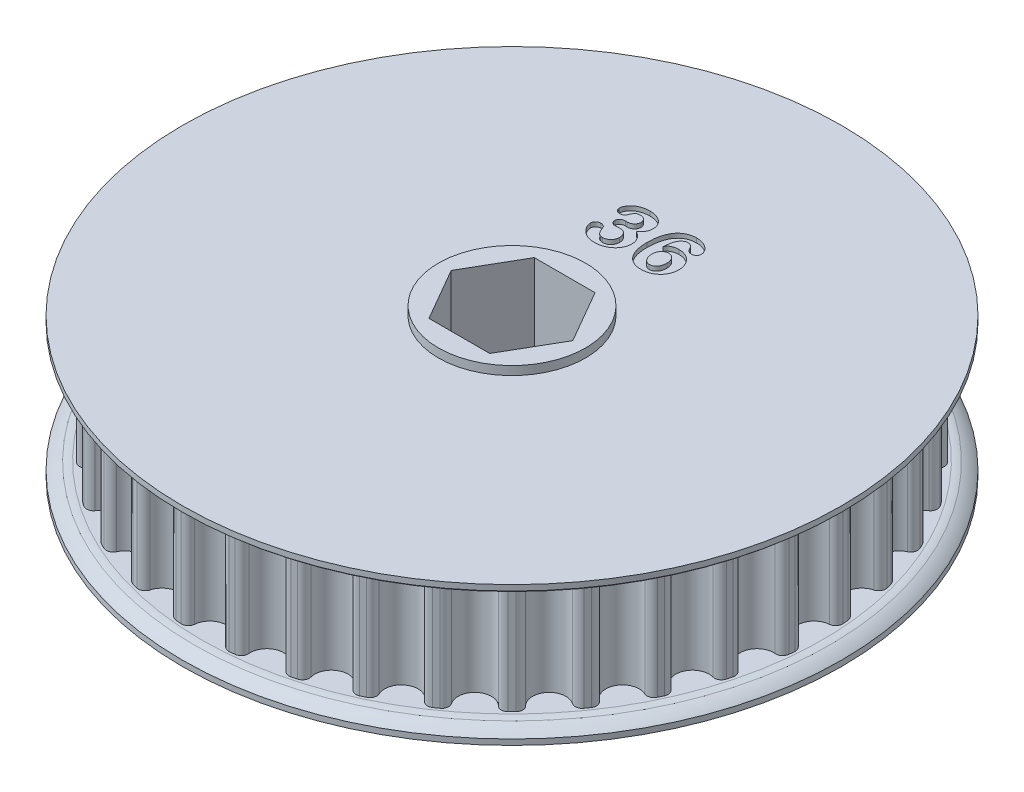
from build123d import *

# Parameters (mm, degrees)
SKETCH1_R               = 28.076389218
TOOTHOD_DEPTH           = 5.08
TOOTHPROFILE_DEPTH      = 11.16
TOOTHPATTERN_COUNT      = 36
SKETCH6_W               = 6.7056
SKETCH6_H               = 0.79375
BORE_DEPTH              = 8.14375
BORE_DEPTH_BACK         = 8.14375
LARGE_TOOTH_COUNT_DEPTH = 0.4


with BuildPart() as part:
    # Sketch1 → ToothOD (new body, symmetric)
    with BuildSketch(Plane(origin=(0, 0, 0), x_dir=(1, 0, 0), z_dir=(0, 1, 0))):
        Circle(SKETCH1_R)
    extrude(amount=TOOTHOD_DEPTH, both=True)

    # Sketch2 → ToothProfile (cut, through all)
    with BuildSketch(Plane(origin=(0, 5.08, 0), x_dir=(1, 0, 0), z_dir=(0, 1, 0))):
        with BuildLine():
            ThreePointArc((-1.519425396, 27.411114635), (0, 26.016389218), (1.519425396, 27.411114635))
            ThreePointArc((1.519425396, 27.411114635), (1.741386688, 27.84115848), (2.201904348, 27.98991334))
            ThreePointArc((2.201904348, 27.98991334), (0, 28.076389218), (-2.201904348, 27.98991334))
            ThreePointArc((-2.201904348, 27.98991334), (-1.741386688, 27.84115848), (-1.519425396, 27.411114635))
        make_face()
    toothprofile = extrude(amount=-TOOTHPROFILE_DEPTH, mode=Mode.SUBTRACT)

    # ToothPattern: ToothProfile ×36 about axis
    toothpattern_axis = Axis((0, 0, 0), (0, 1, 0))
    for i in range(1, TOOTHPATTERN_COUNT):
        add(toothprofile.rotate(toothpattern_axis, i * 360 / TOOTHPATTERN_COUNT), mode=Mode.SUBTRACT)

    # Sketch4 → Flange (revolve)
    with BuildSketch(Plane.XY):
        with BuildLine():
            Line((0, -5.08), (28.330389218, -5.08))
            ThreePointArc((28.330389218, -5.08), (28.656145208, -5.105622571), (28.975961546, -5.172637424))
            ThreePointArc((28.975961546, -5.172637424), (29.543690123, -5.454197125), (30.044889218, -5.842))
            Line((30.044889218, -5.842), (30.044889218, -6.35))
            Line((30.044889218, -6.35), (0, -6.35))
            Line((0, -6.35), (0, -5.08))
        make_face()
        with BuildLine():
            Line((30.044889218, 6.35), (30.044889218, 5.842))
            ThreePointArc((30.044889218, 5.842), (29.543690123, 5.454197125), (28.975961546, 5.172637424))
            ThreePointArc((28.975961546, 5.172637424), (28.656145208, 5.105622571), (28.330389218, 5.08))
            Line((28.330389218, 5.08), (0, 5.08))
            Line((0, 5.08), (0, 6.35))
            Line((0, 6.35), (30.044889218, 6.35))
        make_face()
    revolve(axis=Axis((0, 7.858125, 0), (0, -1, 0)))

    # Sketch6 → TopBearingBoss (revolve)
    with BuildSketch(Plane.XY):
        with Locations((3.3528, 6.746875)):
            Rectangle(SKETCH6_W, SKETCH6_H)
    topbearingboss = revolve(axis=Axis((0, 7.858125, 0), (0, -1, 0)))

    # BottomBearingBoss: TopBearingBoss across plane
    add(topbearingboss.mirror(Plane.ZX))

    # Sketch7 → Bore (cut, two sides)
    with BuildSketch(Plane.XZ) as bore_sk:
        Polygon((2.771627702, 4.8006), (-2.771627702, 4.8006), (-5.543255405, 0), (-2.771627702, -4.8006), (2.771627702, -4.8006), (5.543255405, 0), align=None)
    extrude(amount=BORE_DEPTH, mode=Mode.SUBTRACT)
    extrude(bore_sk.sketch, amount=-BORE_DEPTH_BACK, mode=Mode.SUBTRACT)

    # Sketch9 → Large Tooth Count (cut)
    with BuildSketch(Plane(origin=(0, 6.35, 0), x_dir=(1, 0, 0), z_dir=(0, 1, 0))):
        with BuildLine():
            add(Edge.make_bspline(
                [(-2.157015625, 12.6425445), (-2.111884403, 12.64443398), (-2.023962766, 12.648114937), (-1.897216459, 12.67726646), (-1.781104595, 12.726731958), (-1.693601534, 12.783712382), (-1.631693921, 12.838847998), (-1.590575404, 12.884451281), (-1.556709124, 12.934773106), (-1.528450042, 12.988929014), (-1.506916326, 13.047690391), (-1.490776301, 13.110447299), (-1.481972669, 13.17774376), (-1.480898163, 13.223941999), (-1.48034375, 13.247778875)],
                knots=[0, 0, 0, 0, 0.000135302, 0.000263586, 0.000387613, 0.000512274, 0.000574813, 0.000635952, 0.000695944, 0.000756297, 0.000818773, 0.000883265, 0.000950339, 0.001021838, 0.001021838, 0.001021838, 0.001021838], degree=3))
            add(Edge.make_bspline(
                [(-1.48034375, 13.247778875), (-1.482238566, 13.283364795), (-1.485952272, 13.353110697), (-1.515752857, 13.453681059), (-1.565885328, 13.545781804), (-1.63405775, 13.628860361), (-1.719648386, 13.698830979), (-1.820907936, 13.750391837), (-1.937030222, 13.780560101), (-2.018917057, 13.783832281), (-2.061765625, 13.7855445)],
                knots=[0, 0, 0, 0, 0.000106627, 0.000208981, 0.000311527, 0.000419384, 0.000529405, 0.000640782, 0.000757742, 0.000886119, 0.000886119, 0.000886119, 0.000886119], degree=3))
            add(Edge.make_bspline(
                [(-2.061765625, 13.7855445), (-2.087894348, 13.784798264), (-2.137273817, 13.783387987), (-2.207643435, 13.777621349), (-2.269228007, 13.763082752), (-2.339645218, 13.740430156), (-2.416427882, 13.698077136), (-2.478616997, 13.637961207), (-2.522489539, 13.58024074), (-2.555638687, 13.527943844), (-2.589514573, 13.466379276), (-2.635682542, 13.375118229), (-2.687950603, 13.258408518), (-2.730118411, 13.166063409), (-2.75034375, 13.121771063)],
                knots=[0, 0, 0, 0, 7.8439e-05, 0.000148239, 0.000211303, 0.00026778, 0.000369932, 0.000470998, 0.000524778, 0.000587255, 0.000656544, 0.000735528, 0.000894011, 0.001040092, 0.001040092, 0.001040092, 0.001040092], degree=3))
            add(Edge.make_bspline(
                [(-2.75034375, 13.121771063), (-2.757771996, 13.110721583), (-2.773641193, 13.087116227), (-2.810649943, 13.059211151), (-2.855633248, 13.030698188), (-2.931490979, 12.99738509), (-3.039950355, 12.96480618), (-3.131711281, 12.961008264), (-3.17896875, 12.959052313)],
                knots=[0, 0, 0, 0, 3.9687e-05, 8.4786e-05, 0.000137372, 0.000199532, 0.000332685, 0.000474078, 0.000474078, 0.000474078, 0.000474078], degree=3))
            add(Edge.make_bspline(
                [(-3.17896875, 12.959052313), (-3.204938271, 12.960613704), (-3.256573514, 12.963718221), (-3.331495307, 12.987841238), (-3.40230673, 13.026682965), (-3.467997078, 13.079340406), (-3.523717873, 13.145871748), (-3.565406261, 13.223624155), (-3.589579301, 13.312181316), (-3.592294359, 13.374298209), (-3.593703125, 13.406528875)],
                knots=[0, 0, 0, 0, 7.7797e-05, 0.000154683, 0.00023371, 0.00031909, 0.000405729, 0.000492283, 0.000581828, 0.000678397, 0.000678397, 0.000678397, 0.000678397], degree=3))
            add(Edge.make_bspline(
                [(-3.593703125, 13.406528875), (-3.592354178, 13.437737555), (-3.589612878, 13.501159142), (-3.567007679, 13.596325165), (-3.533407682, 13.693049267), (-3.485225112, 13.790535628), (-3.423416275, 13.887134064), (-3.350245812, 13.98260913), (-3.263570061, 14.073922854), (-3.166964607, 14.163585767), (-3.056818069, 14.247189171), (-2.932844482, 14.321039036), (-2.797615103, 14.388315888), (-2.649715523, 14.443686116), (-2.492341254, 14.491317797), (-2.325048482, 14.523079746), (-2.149919042, 14.543581666), (-2.03040642, 14.546206601), (-1.969492188, 14.5475445)],
                knots=[0, 0, 0, 0, 9.3524e-05, 0.000190057, 0.00029204, 0.000400312, 0.000515371, 0.000635635, 0.000760587, 0.000892604, 0.001030718, 0.001174503, 0.001324927, 0.001483211, 0.001647717, 0.001817589, 0.001993338, 0.002176033, 0.002176033, 0.002176033, 0.002176033], degree=3))
            add(Edge.make_bspline(
                [(-1.969492188, 14.5475445), (-1.912894825, 14.546414192), (-1.801724571, 14.544194005), (-1.638349094, 14.52632416), (-1.482271569, 14.495150086), (-1.333430176, 14.453981191), (-1.192945691, 14.401255934), (-1.062121843, 14.338295139), (-0.941526311, 14.263986326), (-0.832317342, 14.180006344), (-0.733755782, 14.089150126), (-0.64868222, 13.991461033), (-0.577666947, 13.887420287), (-0.52013697, 13.778074395), (-0.475258819, 13.664597947), (-0.443320051, 13.547515782), (-0.42390755, 13.427357492), (-0.421762782, 13.346076195), (-0.4206875, 13.30532575)],
                knots=[0, 0, 0, 0, 0.000169768, 0.000333464, 0.000492245, 0.000646797, 0.000796253, 0.000941804, 0.001081684, 0.001220399, 0.001354491, 0.001483205, 0.001608145, 0.001731528, 0.001853131, 0.00197348, 0.002095006, 0.00221719, 0.00221719, 0.00221719, 0.00221719], degree=3))
            add(Edge.make_bspline(
                [(-0.4206875, 13.30532575), (-0.422150739, 13.252260546), (-0.424989309, 13.14931815), (-0.454296651, 13.000359941), (-0.498779455, 12.861412694), (-0.565247949, 12.733853939), (-0.646829155, 12.6159351), (-0.739747774, 12.502422794), (-0.846598571, 12.395561369), (-0.926107915, 12.330976695), (-0.966390625, 12.298255438)],
                knots=[0, 0, 0, 0, 0.000159001, 0.00030845, 0.000453719, 0.000595272, 0.000738099, 0.000883305, 0.001034846, 0.001190468, 0.001190468, 0.001190468, 0.001190468], degree=3))
            add(Edge.make_bspline(
                [(-0.966390625, 12.298255438), (-0.929596957, 12.279117352), (-0.855339609, 12.240492676), (-0.750874003, 12.169172126), (-0.649933688, 12.089772955), (-0.555598855, 12.00089449), (-0.468741546, 11.905809295), (-0.393120482, 11.805619774), (-0.329551688, 11.701407165), (-0.279407628, 11.592893016), (-0.239035274, 11.48150897), (-0.211379469, 11.366015917), (-0.194077842, 11.247061226), (-0.191698936, 11.166228434), (-0.1905, 11.125489813)],
                knots=[0, 0, 0, 0, 0.000124321, 0.000250905, 0.000378744, 0.000509306, 0.000639252, 0.000764665, 0.000885308, 0.001004709, 0.001122709, 0.001240144, 0.001360395, 0.001482579, 0.001482579, 0.001482579, 0.001482579], degree=3))
            add(Edge.make_bspline(
                [(-0.1905, 11.125489813), (-0.192094678, 11.076452759), (-0.195290193, 10.97818928), (-0.219203507, 10.831631831), (-0.256780918, 10.685916403), (-0.310455948, 10.542693806), (-0.378572049, 10.403116493), (-0.464141536, 10.270797744), (-0.563229415, 10.144043845), (-0.678927942, 10.0263175), (-0.807544592, 9.917389593), (-0.94923826, 9.819008261), (-1.105358046, 9.735376279), (-1.272377153, 9.661545302), (-1.451089398, 9.60293784), (-1.639934199, 9.56185274), (-1.837742142, 9.53483438), (-1.973038792, 9.532323073), (-2.041921875, 9.5310445)],
                knots=[0, 0, 0, 0, 0.000147058, 0.000294684, 0.00044437, 0.00059789, 0.00075275, 0.000909359, 0.001069741, 0.001234626, 0.00140359, 0.001574776, 0.001751042, 0.001934092, 0.002122035, 0.002314133, 0.002513256, 0.002719784, 0.002719784, 0.002719784, 0.002719784], degree=3))
            add(Edge.make_bspline(
                [(-2.041921875, 9.5310445), (-2.108499969, 9.53263626), (-2.238253631, 9.53573843), (-2.427698578, 9.563553956), (-2.606627735, 9.607259017), (-2.773658652, 9.670610818), (-2.927580021, 9.746750057), (-3.068531686, 9.8326532), (-3.196190231, 9.926426748), (-3.30841846, 10.030086414), (-3.406020495, 10.139709066), (-3.492980506, 10.250584634), (-3.566957319, 10.364014336), (-3.626709959, 10.478389222), (-3.674158466, 10.58895269), (-3.707794555, 10.692278721), (-3.730935456, 10.786144569), (-3.734099838, 10.846242417), (-3.735585938, 10.874466375)],
                knots=[0, 0, 0, 0, 0.00019963, 0.000389057, 0.000573147, 0.000751169, 0.000923779, 0.001087646, 0.001245802, 0.001398177, 0.00154501, 0.001685723, 0.001820573, 0.00195061, 0.002072423, 0.002180985, 0.002276549, 0.002361171, 0.002361171, 0.002361171, 0.002361171], degree=3))
            add(Edge.make_bspline(
                [(-3.735585938, 10.874466375), (-3.734032608, 10.908737804), (-3.731024388, 10.975108747), (-3.703162094, 11.068925551), (-3.659172955, 11.153112422), (-3.5953715, 11.222975258), (-3.520183416, 11.280795853), (-3.434611134, 11.32294875), (-3.340524194, 11.348714044), (-3.275046292, 11.351349555), (-3.241476563, 11.35270075)],
                knots=[0, 0, 0, 0, 0.000102585, 0.000198668, 0.000291, 0.00038518, 0.000480036, 0.000574106, 0.000669655, 0.00077018, 0.00077018, 0.00077018, 0.00077018], degree=3))
            add(Edge.make_bspline(
                [(-3.241476563, 11.35270075), (-3.218602924, 11.351603225), (-3.173488087, 11.34943852), (-3.106820151, 11.336469932), (-3.04284117, 11.31319361), (-2.983219438, 11.281768881), (-2.929645336, 11.247522156), (-2.8870894, 11.211334238), (-2.852576409, 11.177414837), (-2.840334224, 11.150718847), (-2.834679688, 11.13838825)],
                knots=[0, 0, 0, 0, 6.864e-05, 0.000135383, 0.000202859, 0.000272085, 0.000337306, 0.000392948, 0.000440001, 0.000480389, 0.000480389, 0.000480389, 0.000480389], degree=3))
            add(Edge.make_bspline(
                [(-2.834679688, 11.13838825), (-2.820311557, 11.101274305), (-2.792459848, 11.02933128), (-2.7491029, 10.926277989), (-2.705207879, 10.832244401), (-2.662976882, 10.7459279), (-2.618801115, 10.669123621), (-2.577075586, 10.598841195), (-2.532761662, 10.538726413), (-2.477763144, 10.468824929), (-2.399118743, 10.397704823), (-2.290202773, 10.336113991), (-2.166615271, 10.299170017), (-2.079882194, 10.295134085), (-2.034976563, 10.2930445)],
                knots=[0, 0, 0, 0, 0.000119393, 0.000231435, 0.000335312, 0.000430712, 0.000519567, 0.000601077, 0.000675703, 0.000743419, 0.00086776, 0.000990827, 0.001116082, 0.001250556, 0.001250556, 0.001250556, 0.001250556], degree=3))
            add(Edge.make_bspline(
                [(-2.034976563, 10.2930445), (-2.003806077, 10.294232786), (-1.941674855, 10.29660136), (-1.849507969, 10.314471946), (-1.75889532, 10.341715283), (-1.671599601, 10.382118359), (-1.58781549, 10.431823988), (-1.512118592, 10.49559363), (-1.44314573, 10.569315349), (-1.382772856, 10.65396479), (-1.331662747, 10.747344641), (-1.296477219, 10.849709531), (-1.273414798, 10.958103568), (-1.271154957, 11.032762781), (-1.27, 11.0709195)],
                knots=[0, 0, 0, 0, 9.3455e-05, 0.000186282, 0.000280748, 0.000376658, 0.00047416, 0.000572105, 0.000672493, 0.000776299, 0.00088328, 0.000990602, 0.001099959, 0.001214272, 0.001214272, 0.001214272, 0.001214272], degree=3))
            add(Edge.make_bspline(
                [(-1.27, 11.0709195), (-1.270560286, 11.099383177), (-1.271657679, 11.15513302), (-1.280514674, 11.236154242), (-1.295659925, 11.312416525), (-1.315634417, 11.384013578), (-1.344559164, 11.449800178), (-1.376581011, 11.512164184), (-1.416894679, 11.568397932), (-1.461626204, 11.620680977), (-1.511934133, 11.666930068), (-1.567372981, 11.707500229), (-1.627994429, 11.740745799), (-1.693291801, 11.76915947), (-1.763628774, 11.790420281), (-1.838866572, 11.806791751), (-1.919022226, 11.815316155), (-1.974105141, 11.816460247), (-2.002234375, 11.8170445)],
                knots=[0, 0, 0, 0, 8.538e-05, 0.000167228, 0.000244089, 0.000318503, 0.000389637, 0.000459323, 0.000528414, 0.000596644, 0.000665457, 0.000732933, 0.000802223, 0.000872444, 0.000946194, 0.001022282, 0.001103144, 0.001187533, 0.001187533, 0.001187533, 0.001187533], degree=3))
            add(Edge.make_bspline(
                [(-2.002234375, 11.8170445), (-2.013149109, 11.816737884), (-2.038625164, 11.816022212), (-2.082313291, 11.81411827), (-2.136885798, 11.809957221), (-2.19803711, 11.804265221), (-2.258501955, 11.798317022), (-2.310435325, 11.794275447), (-2.350811539, 11.792287851), (-2.373642425, 11.791555365), (-2.383234375, 11.791247625)],
                knots=[0, 0, 0, 0, 3.2757e-05, 7.6459e-05, 0.000131173, 0.000196927, 0.000260706, 0.000313441, 0.000353178, 0.000381969, 0.000381969, 0.000381969, 0.000381969], degree=3))
            add(Edge.make_bspline(
                [(-2.383234375, 11.791247625), (-2.416103873, 11.792413719), (-2.478614259, 11.794631367), (-2.566842115, 11.815825856), (-2.644072814, 11.850765193), (-2.70956862, 11.900062371), (-2.762416451, 11.962121184), (-2.797566853, 12.037010123), (-2.821995063, 12.120783855), (-2.823809627, 12.180651691), (-2.824757813, 12.211935125)],
                knots=[0, 0, 0, 0, 9.8472e-05, 0.000187271, 0.000270289, 0.000351054, 0.000431341, 0.0005121, 0.000597554, 0.000691078, 0.000691078, 0.000691078, 0.000691078], degree=3))
            add(Edge.make_bspline(
                [(-2.824757813, 12.211935125), (-2.823142272, 12.242905097), (-2.820022845, 12.302704636), (-2.792978858, 12.387374025), (-2.749739761, 12.462964643), (-2.687372417, 12.526690802), (-2.610407925, 12.580733841), (-2.515839245, 12.615994968), (-2.408234977, 12.639836531), (-2.33146158, 12.641609302), (-2.290960938, 12.6425445)],
                knots=[0, 0, 0, 0, 9.2705e-05, 0.000179002, 0.00026392, 0.000351643, 0.00044439, 0.000543698, 0.000652287, 0.000773533, 0.000773533, 0.000773533, 0.000773533], degree=3))
            Line((-2.290960938, 12.6425445), (-2.157015625, 12.6425445))
        make_face()
        with BuildLine():
            add(Edge.make_bspline(
                [(1.447601563, 12.301232), (1.453009879, 12.322245396), (1.463707408, 12.363809428), (1.48930573, 12.422939345), (1.520989673, 12.47868255), (1.559685207, 12.530677031), (1.606344705, 12.577244267), (1.658377002, 12.621608552), (1.717708529, 12.662219731), (1.807322768, 12.709294383), (1.927365138, 12.758241872), (2.079320085, 12.803230441), (2.239913343, 12.827444762), (2.349427302, 12.831158069), (2.4050625, 12.8330445)],
                knots=[0, 0, 0, 0, 6.5009e-05, 0.000128587, 0.000192581, 0.000257073, 0.000322324, 0.000389909, 0.000462012, 0.000537477, 0.000693175, 0.000850179, 0.001011835, 0.001178762, 0.001178762, 0.001178762, 0.001178762], degree=3))
            add(Edge.make_bspline(
                [(2.4050625, 12.8330445), (2.462355944, 12.831529535), (2.57546434, 12.8285387), (2.741556302, 12.804538772), (2.90072962, 12.763423945), (3.052445157, 12.70668638), (3.1959965, 12.636524721), (3.329662088, 12.553837694), (3.452850278, 12.459242339), (3.563565946, 12.351469737), (3.664347231, 12.234239054), (3.75268027, 12.107369441), (3.827722686, 11.970840658), (3.88927345, 11.827006132), (3.939068311, 11.678397036), (3.975084362, 11.527065608), (3.9964143, 11.373819845), (3.999138881, 11.271075564), (4.0005, 11.219747625)],
                knots=[0, 0, 0, 0, 0.000171832, 0.00033923, 0.000502148, 0.000664145, 0.000824333, 0.000980725, 0.001134926, 0.0012893, 0.001443409, 0.001598091, 0.001752187, 0.001909958, 0.002066836, 0.002221821, 0.002376032, 0.002529978, 0.002529978, 0.002529978, 0.002529978], degree=3))
            add(Edge.make_bspline(
                [(4.0005, 11.219747625), (3.997850892, 11.144481621), (3.992629458, 10.996131166), (3.950418741, 10.778252474), (3.881897673, 10.569286396), (3.801157402, 10.404307837), (3.725072769, 10.27834675), (3.660166448, 10.189465496), (3.590675899, 10.104607669), (3.515025506, 10.024693984), (3.43247029, 9.950854099), (3.344866238, 9.88052633), (3.250525665, 9.816651293), (3.151379545, 9.756963092), (3.047647798, 9.703090996), (2.938962341, 9.658205487), (2.827812576, 9.61759748), (2.712185632, 9.586250644), (2.593225173, 9.561547637), (2.470694395, 9.543320757), (2.344689434, 9.533834398), (2.259555191, 9.53198087), (2.216546875, 9.5310445)],
                knots=[0, 0, 0, 0, 0.000225655, 0.000444769, 0.000663144, 0.000883689, 0.000994126, 0.001104276, 0.00121353, 0.001323012, 0.001434004, 0.001545571, 0.001659781, 0.001775489, 0.001892638, 0.002010023, 0.002128022, 0.002247415, 0.002369034, 0.002492373, 0.002618771, 0.002747816, 0.002747816, 0.002747816, 0.002747816], degree=3))
            add(Edge.make_bspline(
                [(2.216546875, 9.5310445), (2.169533289, 9.53154025), (2.07727261, 9.532513122), (1.941632495, 9.548090923), (1.810570719, 9.567240853), (1.684978997, 9.599324829), (1.56329832, 9.636950514), (1.447660878, 9.686665279), (1.335319823, 9.741587568), (1.229537567, 9.807453121), (1.128964082, 9.881371586), (1.033188343, 9.962354746), (0.945264872, 10.053013065), (0.863171408, 10.151279999), (0.786777878, 10.257109286), (0.717395456, 10.371876531), (0.653911432, 10.494225195), (0.59608377, 10.624274424), (0.546192482, 10.762496385), (0.500685089, 10.907494566), (0.464994093, 11.060625275), (0.433755593, 11.220701505), (0.410185375, 11.388302619), (0.393891402, 11.563132462), (0.38204873, 11.745114759), (0.381354334, 11.868948792), (0.381, 11.93213825)],
                knots=[0, 0, 0, 0, 0.000140947, 0.000276597, 0.000409213, 0.000537957, 0.000665038, 0.000790893, 0.000915135, 0.001039871, 0.0011641, 0.001289368, 0.00141566, 0.001542443, 0.001673239, 0.001806816, 0.001944387, 0.002086533, 0.002233437, 0.002385022, 0.002542167, 0.002704843, 0.002874205, 0.003049643, 0.003231541, 0.003421072, 0.003421072, 0.003421072, 0.003421072], degree=3))
            add(Edge.make_bspline(
                [(0.381, 11.93213825), (0.382362514, 12.033395978), (0.385025082, 12.23126951), (0.410432123, 12.519874591), (0.450601925, 12.792702414), (0.50666856, 13.048858723), (0.578461946, 13.286965623), (0.665538683, 13.504912727), (0.766670401, 13.702231072), (0.883464174, 13.878059879), (1.013966085, 14.03412753), (1.158335063, 14.170044597), (1.31700515, 14.285112815), (1.488245224, 14.381049202), (1.673062745, 14.455498093), (1.869453427, 14.509072344), (2.077565864, 14.541392526), (2.220068347, 14.545462885), (2.292945313, 14.5475445)],
                knots=[0, 0, 0, 0, 0.000303713, 0.000593503, 0.000868389, 0.001130547, 0.001379443, 0.001613618, 0.001833725, 0.002043415, 0.002245532, 0.002442778, 0.002636671, 0.002832109, 0.003030174, 0.003232845, 0.003441649, 0.003660202, 0.003660202, 0.003660202, 0.003660202], degree=3))
            add(Edge.make_bspline(
                [(2.292945313, 14.5475445), (2.367513826, 14.54574969), (2.513208573, 14.542242921), (2.724510265, 14.506103442), (2.923143918, 14.450260135), (3.105512799, 14.370429952), (3.269826261, 14.27628259), (3.413656116, 14.171495364), (3.535182954, 14.057622638), (3.631275314, 13.933929601), (3.705135168, 13.808448608), (3.760020033, 13.685995045), (3.793967421, 13.566425653), (3.798754158, 13.487420902), (3.801070313, 13.449192938)],
                knots=[0, 0, 0, 0, 0.000223509, 0.0004367, 0.000641131, 0.000841113, 0.001032235, 0.001208258, 0.001373885, 0.001530088, 0.001676428, 0.00180971, 0.001931975, 0.002046597, 0.002046597, 0.002046597, 0.002046597], degree=3))
            add(Edge.make_bspline(
                [(3.801070313, 13.449192938), (3.799601046, 13.42547896), (3.796603269, 13.377094782), (3.768961689, 13.306029844), (3.728027039, 13.235017818), (3.671021084, 13.166977969), (3.600760369, 13.105228394), (3.513789835, 13.062680082), (3.415028867, 13.03598358), (3.34485337, 13.033033326), (3.307953125, 13.031482)],
                knots=[0, 0, 0, 0, 7.0891e-05, 0.000144641, 0.000225988, 0.000316184, 0.000409813, 0.000504327, 0.000603966, 0.000714461, 0.000714461, 0.000714461, 0.000714461], degree=3))
            add(Edge.make_bspline(
                [(3.307953125, 13.031482), (3.281406916, 13.032636954), (3.228694625, 13.034930323), (3.151295917, 13.053061051), (3.078352533, 13.084985117), (3.008723369, 13.125908604), (2.946420213, 13.179169588), (2.890788452, 13.240814306), (2.846238753, 13.313336941), (2.823461153, 13.36587697), (2.811859375, 13.39263825)],
                knots=[0, 0, 0, 0, 7.9598e-05, 0.000158056, 0.000236746, 0.000317742, 0.000399427, 0.000481659, 0.000565901, 0.000653355, 0.000653355, 0.000653355, 0.000653355], degree=3))
            add(Edge.make_bspline(
                [(2.811859375, 13.39263825), (2.799506329, 13.421533329), (2.775304886, 13.478143057), (2.72415789, 13.554813016), (2.663714481, 13.622352813), (2.593835938, 13.680237415), (2.516396614, 13.727070277), (2.431842539, 13.761491383), (2.340828568, 13.781417182), (2.278157852, 13.784153881), (2.2463125, 13.7855445)],
                knots=[0, 0, 0, 0, 9.4106e-05, 0.000184368, 0.000275005, 0.000365202, 0.000455556, 0.000545468, 0.000637912, 0.000733415, 0.000733415, 0.000733415, 0.000733415], degree=3))
            add(Edge.make_bspline(
                [(2.2463125, 13.7855445), (2.224717521, 13.784623062), (2.180304603, 13.782728002), (2.113385725, 13.765389896), (2.044326016, 13.739541377), (1.97407994, 13.70249927), (1.903707052, 13.655192019), (1.83548507, 13.595216235), (1.768913857, 13.524046445), (1.729140583, 13.469498921), (1.708546875, 13.441255438)],
                knots=[0, 0, 0, 0, 6.4683e-05, 0.000133029, 0.000206188, 0.000285625, 0.000370659, 0.000459983, 0.000557566, 0.000662344, 0.000662344, 0.000662344, 0.000662344], degree=3))
            add(Edge.make_bspline(
                [(1.708546875, 13.441255438), (1.690316305, 13.412540787), (1.651993771, 13.352179635), (1.605936116, 13.248176189), (1.565937201, 13.128709406), (1.53044734, 12.99381257), (1.500781627, 12.843032474), (1.477887866, 12.676660945), (1.458476926, 12.49437507), (1.451328579, 12.367422648), (1.447601563, 12.301232)],
                knots=[0, 0, 0, 0, 0.000101925, 0.000214257, 0.000340078, 0.000479662, 0.000632411, 0.000800791, 0.000983337, 0.001182193, 0.001182193, 0.001182193, 0.001182193], degree=3))
        make_face()
        with BuildLine():
            add(Edge.make_bspline(
                [(2.212578125, 10.2930445), (2.237439246, 10.293755054), (2.286461915, 10.295156167), (2.358198055, 10.30782921), (2.427029087, 10.326108949), (2.492228211, 10.353459978), (2.554206493, 10.388381777), (2.612640232, 10.431548854), (2.668765789, 10.481112161), (2.720073976, 10.539157632), (2.767254555, 10.602682763), (2.80852425, 10.672150424), (2.842971429, 10.746750978), (2.872055965, 10.826271709), (2.893687314, 10.911444906), (2.909169399, 11.001355628), (2.919720354, 11.096468491), (2.92056554, 11.161509339), (2.921, 11.194942938)],
                knots=[0, 0, 0, 0, 7.452e-05, 0.000146943, 0.000217952, 0.000287787, 0.000358427, 0.000430864, 0.00050535, 0.000582639, 0.00066281, 0.000742445, 0.000824563, 0.000908993, 0.000996108, 0.001087782, 0.00118256, 0.001282815, 0.001282815, 0.001282815, 0.001282815], degree=3))
            add(Edge.make_bspline(
                [(2.921, 11.194942938), (2.919903701, 11.239646659), (2.91778285, 11.326128428), (2.900226752, 11.450791052), (2.869183792, 11.564870051), (2.827336011, 11.668668458), (2.776405368, 11.762192361), (2.714833277, 11.843673021), (2.645517535, 11.913790958), (2.567096304, 11.970678192), (2.48311164, 12.015203199), (2.394263088, 12.047217131), (2.301536749, 12.068249477), (2.237828176, 12.070106199), (2.205632813, 12.0710445)],
                knots=[0, 0, 0, 0, 0.000134078, 0.00025938, 0.000376597, 0.000487881, 0.000594467, 0.000695075, 0.000793296, 0.000889149, 0.000984574, 0.00107748, 0.001171863, 0.00126829, 0.00126829, 0.00126829, 0.00126829], degree=3))
            add(Edge.make_bspline(
                [(2.205632813, 12.0710445), (2.179448648, 12.069682294), (2.126625412, 12.066934215), (2.047043803, 12.051143309), (1.968833386, 12.020948316), (1.890251242, 11.983300712), (1.815635893, 11.932255193), (1.746350753, 11.86894767), (1.683763686, 11.792505835), (1.627434041, 11.704663662), (1.580201934, 11.605422774), (1.547948098, 11.494560836), (1.527837401, 11.373937552), (1.525307523, 11.289946165), (1.524, 11.246536688)],
                knots=[0, 0, 0, 0, 7.8609e-05, 0.000158583, 0.00024208, 0.000329494, 0.000419483, 0.000512187, 0.000610133, 0.000714995, 0.000824626, 0.000938572, 0.001060256, 0.001190418, 0.001190418, 0.001190418, 0.001190418], degree=3))
            add(Edge.make_bspline(
                [(1.524, 11.246536688), (1.524481698, 11.211456696), (1.525424433, 11.142801439), (1.535399272, 11.042602078), (1.552410881, 10.94782419), (1.57523039, 10.85827354), (1.603556055, 10.773623403), (1.639660922, 10.69460123), (1.68225376, 10.621194212), (1.73103065, 10.553594935), (1.783863204, 10.493187931), (1.8387925, 10.439408234), (1.896445464, 10.39512814), (1.955490714, 10.357344659), (2.017061279, 10.32894993), (2.080384473, 10.307238619), (2.145988259, 10.295436874), (2.190377395, 10.293842106), (2.212578125, 10.2930445)],
                knots=[0, 0, 0, 0, 0.000105214, 0.000205915, 0.00030167, 0.000393837, 0.000482946, 0.000569084, 0.000654001, 0.000737162, 0.000818739, 0.000894522, 0.000967359, 0.001036457, 0.001104369, 0.001170258, 0.001236816, 0.001303411, 0.001303411, 0.001303411, 0.001303411], degree=3))
        make_face(mode=Mode.SUBTRACT)
    extrude(amount=-LARGE_TOOTH_COUNT_DEPTH, mode=Mode.SUBTRACT)


solid = part.part
